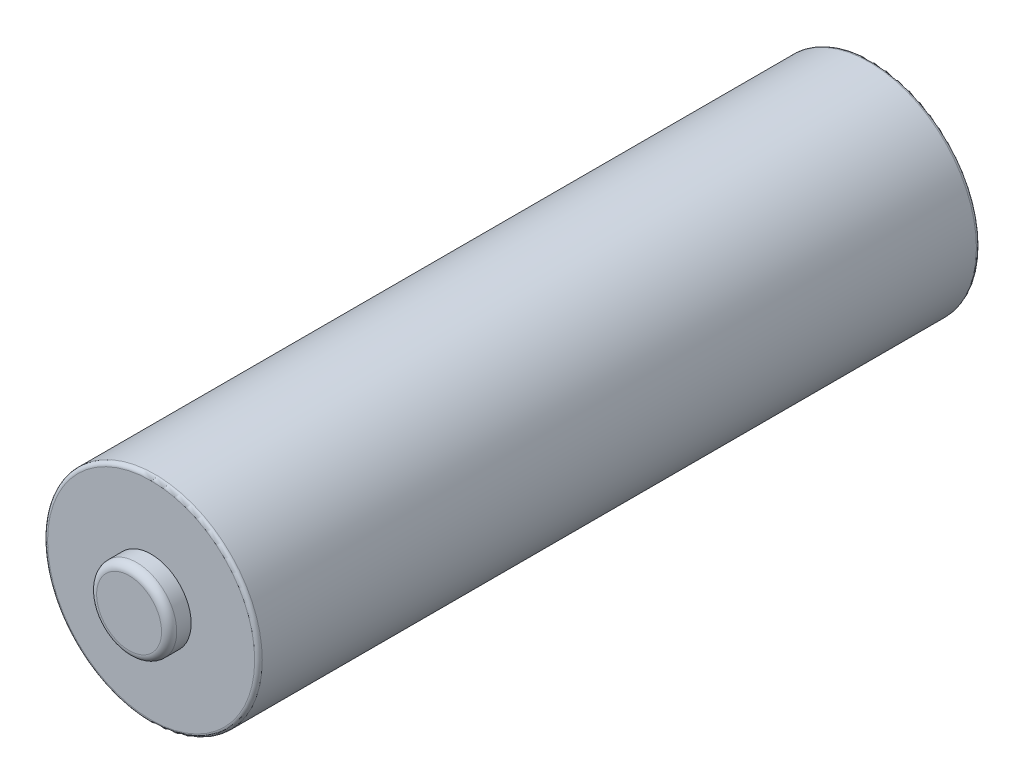
from build123d import *

# Parameters (mm, degrees)
SKETCH1_R           = 7.065
BOSS_EXTRUDE1_DEPTH = 47.5
SKETCH2_R           = 2.635
BOSS_EXTRUDE2_DEPTH = 1.45
FILLET2_R           = 0.25
SKETCH3_R           = 4.435
BOSS_EXTRUDE3_DEPTH = 1.2
FILLET1_R           = 0.5


with BuildPart() as part:
    # Sketch1 → Boss-Extrude1 (new body)
    with BuildSketch(Plane.XY):
        Circle(SKETCH1_R)
    extrude(amount=BOSS_EXTRUDE1_DEPTH)

    # Sketch2 → Boss-Extrude2 (add)
    with BuildSketch(Plane.XY.offset(47.5)):
        Circle(SKETCH2_R)
    extrude(amount=BOSS_EXTRUDE2_DEPTH)

    # Fillet2
    fillet2_edges = [part.edges().sort_by_distance(p)[0] for p in [
        (-7.065, 0, 0),
        (-7.065, 0, 47.5),
    ]]
    fillet(fillet2_edges, radius=FILLET2_R)

    # Sketch3 → Boss-Extrude3 (add)
    with BuildSketch(Plane(origin=(0, 0, 0), x_dir=(-1, 0, 0), z_dir=(0, 0, -1))):
        Circle(SKETCH3_R)
    extrude(amount=BOSS_EXTRUDE3_DEPTH)

    # Fillet1
    fillet1_edges = [part.edges().sort_by_distance(p)[0] for p in [
        (4.435, 0, -1.2),
        (-2.635, 0, 48.95),
    ]]
    fillet(fillet1_edges, radius=FILLET1_R)


solid = part.part
